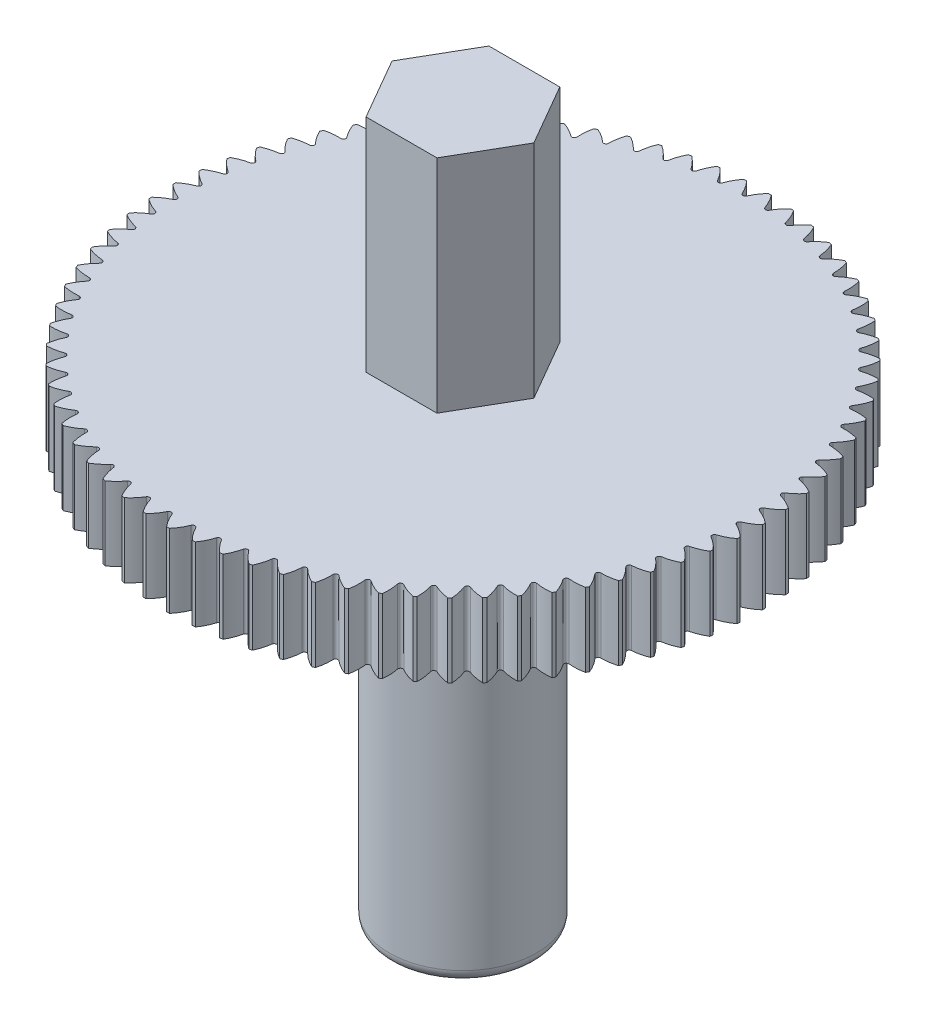
from build123d import *

# Parameters (mm, degrees)
CUT_EXTRUDE1_DEPTH = 10
CIRPATTERN1_COUNT  = 75
SKETCH3_R          = 3
CUT_EXTRUDE2_DEPTH = 9
FILLET1_R          = 0.5


with BuildPart() as part:
    # Sketch1 → Revolve1 (revolve)
    with BuildSketch(Plane.XY):
        Polygon((0, 0), (0, 29), (3, 29), (3, 20), (12, 20), (12, 17), (3, 17), (3, 0), align=None)
    revolve(axis=Axis((0, 0, 0), (0, 1, 0)))

    # Sketch2 → Cut-Extrude1 (cut)
    with BuildSketch(Plane(origin=(0, 20, 0), x_dir=(1, 0, 0), z_dir=(0, 1, 0))):
        with BuildLine():
            Line((-0.45, 12), (0.45, 12))
            ThreePointArc((0.45, 12), (0.248504486, 11.744148972), (0.091203345, 11.458988418))
            ThreePointArc((0.091203345, 11.458988418), (0, 11.4), (-0.091203345, 11.458988418))
            ThreePointArc((-0.091203345, 11.458988418), (-0.248504486, 11.744148972), (-0.45, 12))
        make_face()
    cut_extrude1 = extrude(amount=-CUT_EXTRUDE1_DEPTH, mode=Mode.SUBTRACT)

    # CirPattern1: Cut-Extrude1 ×75 about axis
    cirpattern1_axis = Axis((0, 0, 0), (0, 1, 0))
    for i in range(1, CIRPATTERN1_COUNT):
        add(cut_extrude1.rotate(cirpattern1_axis, i * 360 / CIRPATTERN1_COUNT), mode=Mode.SUBTRACT)

    # Sketch3 → Cut-Extrude2 (cut)
    with BuildSketch(Plane(origin=(0, 29, 0), x_dir=(1, 0, 0), z_dir=(0, 1, 0))):
        Circle(SKETCH3_R)
        Polygon((-1.443375673, 2.5), (-2.886751346, 0), (-1.443375673, -2.5), (1.443375673, -2.5), (2.886751346, 0), (1.443375673, 2.5), align=None, mode=Mode.SUBTRACT)
    extrude(amount=-CUT_EXTRUDE2_DEPTH, mode=Mode.SUBTRACT)

    # Fillet1
    fillet1_edges = [part.edges().sort_by_distance(p)[0] for p in [
        (-3, 0, 0),
    ]]
    fillet(fillet1_edges, radius=FILLET1_R)


solid = part.part
